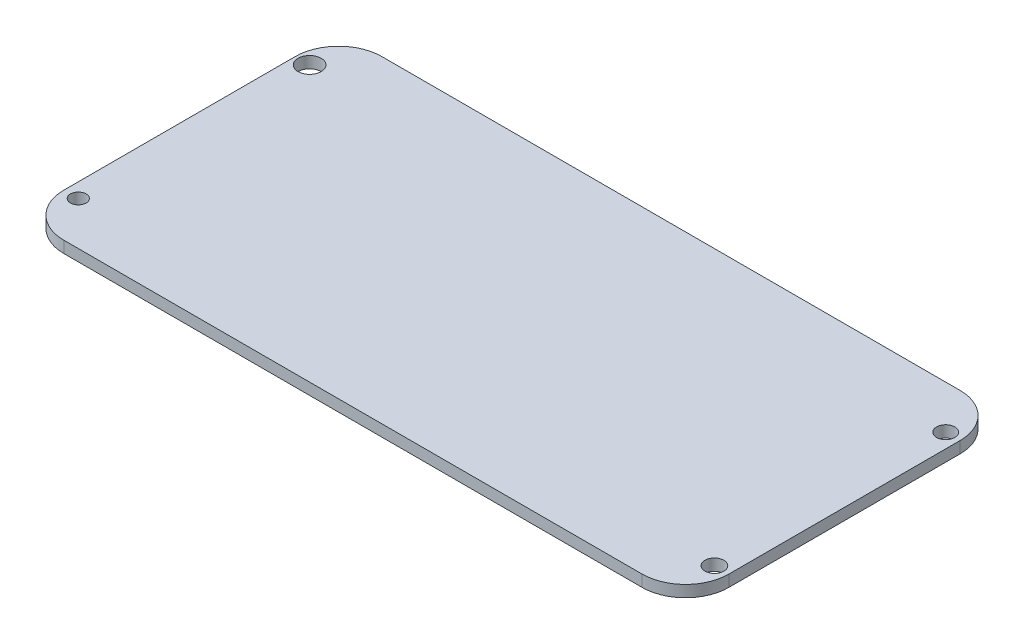
from build123d import *

# Parameters (mm, degrees)
SKETCH1_W           = 92
SKETCH1_H           = 44
SKETCH1_R           = 1.090391873
SKETCH1_R_2         = 1.6
SKETCH1_R_3         = 1.26453084
SKETCH1_R_4         = 1.308726881
BOSS_EXTRUDE1_DEPTH = 1.6
FILLET1_R           = 6


with BuildPart() as part:
    # Sketch1 → Boss-Extrude1 (new body)
    with BuildSketch(Plane(origin=(0, 0, 0), x_dir=(1, 0, 0), z_dir=(0, 1, 0))):
        with Locations((46, 22)):
            Rectangle(SKETCH1_W, SKETCH1_H)
        with Locations((2, 6)):
            Circle(SKETCH1_R, mode=Mode.SUBTRACT)
        with Locations((2, 38)):
            Circle(SKETCH1_R_2, mode=Mode.SUBTRACT)
        with Locations((90, 38)):
            Circle(SKETCH1_R_3, mode=Mode.SUBTRACT)
        with Locations((90, 6)):
            Circle(SKETCH1_R_4, mode=Mode.SUBTRACT)
    extrude(amount=BOSS_EXTRUDE1_DEPTH)

    # Fillet1
    fillet1_edges = [part.edges().sort_by_distance(p)[0] for p in [
        (0, 0.8, -44),
        (92, 0.8, -44),
        (92, 0.8, 0),
        (0, 0.8, 0),
    ]]
    fillet(fillet1_edges, radius=FILLET1_R)


solid = part.part
